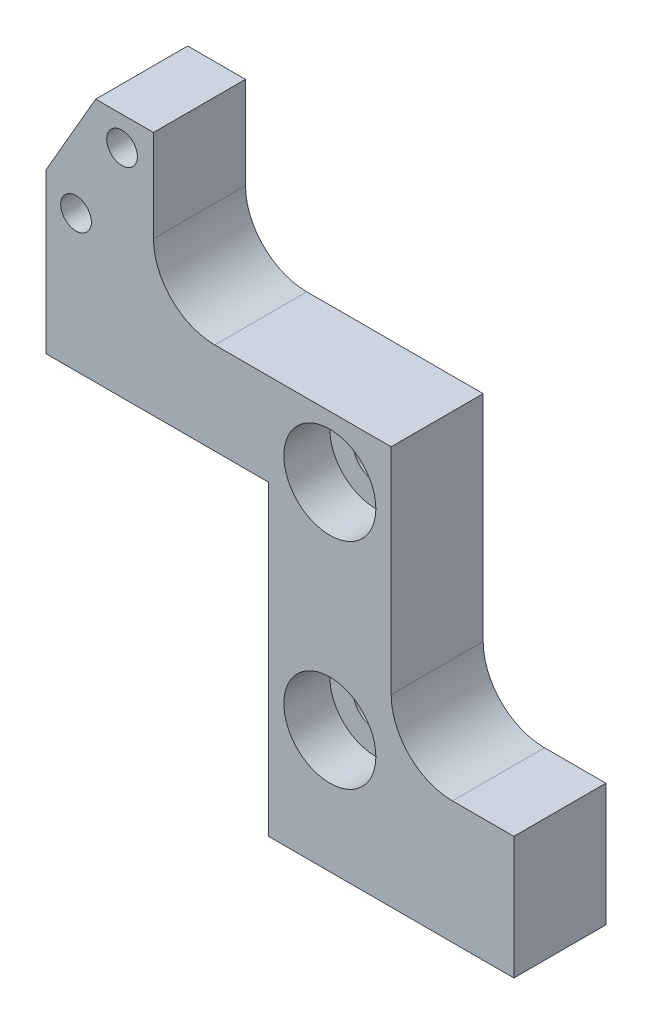
from build123d import *

# Parameters (mm, degrees)
SKETCH1_R                       = 1
BOSS_EXTRUDE1_DEPTH             = 6
FILLET1_R                       = 4
FILLET2_R                       = 4
SKETCH2_R                       = 3
CUT_EXTRUDE1_DEPTH              = 3
SKETCH3_R                       = 1.5
CUT_EXTRUDE2_DEPTH              = 4
M3X0_5_TAPPED_HOLE1_D           = 2.5
M3X0_5_TAPPED_HOLE1_DEPTH       = 4
M3X0_5_TAPPED_HOLE1_CSINK_D     = 3.05
M3X0_5_TAPPED_HOLE1_CSINK_ANGLE = 90
M3X0_5_TAPPED_HOLE1_TIP         = 0.751075774
F_2_0_2_DIAMETER_HOLE1_D        = 2
F_2_0_2_DIAMETER_HOLE1_DEPTH    = 3
F_2_0_2_DIAMETER_HOLE1_TIP      = 0.600860619


with BuildPart() as part:
    # Sketch1 → Boss-Extrude1 (new body)
    with BuildSketch(Plane.XY):
        Polygon((-27.266838493, 36), (-30.5, 30.4), (-30.5, 26), (-30.5, 20), (-16, 20), (-16, 8), (-16, 0), (0, 0), (0, 8), (-8, 8), (-8, 26), (-16, 26), (-23.5, 26), (-23.5, 36), align=None)
        with Locations((-28.55, 28.91)):
            Circle(SKETCH1_R, mode=Mode.SUBTRACT)
        with Locations((-25.55, 34.106152423)):
            Circle(SKETCH1_R, mode=Mode.SUBTRACT)
    extrude(amount=BOSS_EXTRUDE1_DEPTH)

    # Fillet1
    fillet1_edges = [part.edges().sort_by_distance(p)[0] for p in [
        (-23.5, 26, 3),
    ]]
    fillet(fillet1_edges, radius=FILLET1_R)

    # Fillet2
    fillet2_edges = [part.edges().sort_by_distance(p)[0] for p in [
        (-8, 8, 3),
    ]]
    fillet(fillet2_edges, radius=FILLET2_R)

    # Sketch2 → Cut-Extrude1 (cut)
    with BuildSketch(Plane.XY.offset(6)):
        with Locations((-12, 22)):
            Circle(SKETCH2_R)
        with Locations((-12, 8)):
            Circle(SKETCH2_R)
    extrude(amount=-CUT_EXTRUDE1_DEPTH, mode=Mode.SUBTRACT)

    # Sketch3 → Cut-Extrude2 (cut, through all)
    with BuildSketch(Plane.XY.offset(3)):
        with Locations((-12, 22)):
            Circle(SKETCH3_R)
        with Locations((-12, 8)):
            Circle(SKETCH3_R)
    extrude(amount=-CUT_EXTRUDE2_DEPTH, mode=Mode.SUBTRACT)

    # M3x0.5 Tapped Hole1
    with Locations(Plane(origin=(0, 0, 0), x_dir=(-1, 0, 0), z_dir=(0, -1, 0))):
        with Locations((13, -3), (3, -3)):
            CounterSinkHole(M3X0_5_TAPPED_HOLE1_D / 2, M3X0_5_TAPPED_HOLE1_CSINK_D / 2, depth=M3X0_5_TAPPED_HOLE1_DEPTH, counter_sink_angle=M3X0_5_TAPPED_HOLE1_CSINK_ANGLE)
            with Locations((0, 0, -(M3X0_5_TAPPED_HOLE1_DEPTH + M3X0_5_TAPPED_HOLE1_TIP / 2))):  # 118° drill point
                Cone(0, M3X0_5_TAPPED_HOLE1_D / 2, M3X0_5_TAPPED_HOLE1_TIP, mode=Mode.SUBTRACT)

    # Ø2.0 (2) Diameter Hole1
    with Locations(Plane(origin=(0, 0, 0), x_dir=(-1, 0, 0), z_dir=(0, -1, 0))):
        with Locations((8, -3)):
            Hole(F_2_0_2_DIAMETER_HOLE1_D / 2, depth=F_2_0_2_DIAMETER_HOLE1_DEPTH)
            with Locations((0, 0, -(F_2_0_2_DIAMETER_HOLE1_DEPTH + F_2_0_2_DIAMETER_HOLE1_TIP / 2))):  # 118° drill point
                Cone(0, F_2_0_2_DIAMETER_HOLE1_D / 2, F_2_0_2_DIAMETER_HOLE1_TIP, mode=Mode.SUBTRACT)


solid = part.part
